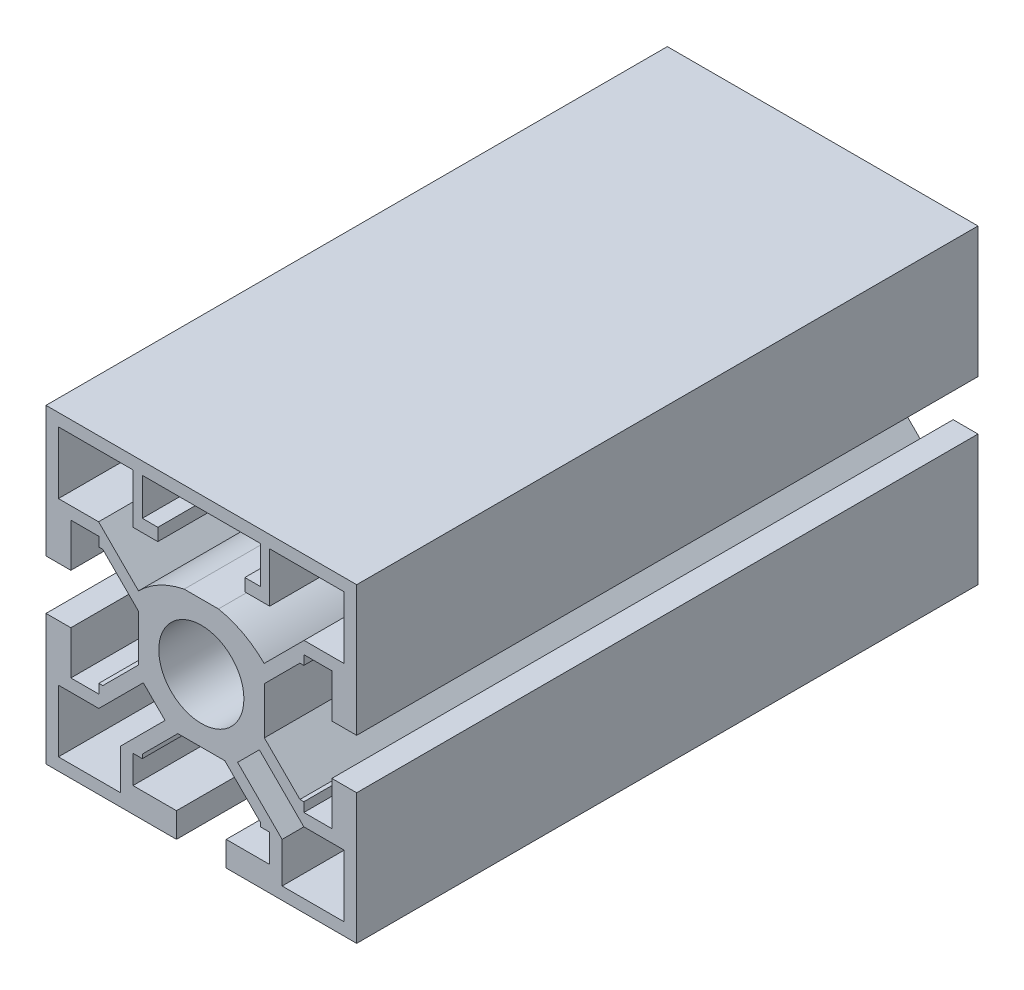
from build123d import *

# Parameters (mm, degrees)
SKETCH_A01_8_R     = 6.85
SKETCH_A01_8_W     = 10
SKETCH_A01_8_H     = 10
EXTRUDE1_DEPTH     = 100
CUT_EXTRUDE1_DEPTH = 101
CIRPATTERN1_COUNT  = 2
CIRPATTERN1_ANGLE  = 90
CUT_EXTRUDE2_DEPTH = 101
EXTRUDE3_DEPTH     = 100


with BuildPart() as part:
    # Sketch A01-8 → Extrude1 (new body)
    with BuildSketch(Plane.XY):
        Polygon((-16.5, -11), (-16.5, -9.5), (-15.863961, -9.5), (-10.14602885, -3.78206785), (-10.14602885, 3.78206785), (-15.863961, 9.5), (-16.5, 9.5), (-16.5, 11), (-21, 11), (-21, 4), (-25, 4), (-25, 25), (25, 25), (25, 4), (21, 4), (21, 11), (16.5, 11), (16.5, 9.5), (15.863961, 9.5), (10.14602885, 3.78206785), (10.14602885, -3.78206785), (15.863961, -9.5), (16.5, -9.5), (16.5, -11), (21, -11), (21, -4), (25, -4), (25, -25), (4, -25), (4, -21), (11, -21), (11, -16.5), (9.5, -16.5), (9.5, -15.863961), (3.78206785, -10.14602885), (-3.78206785, -10.14602885), (-9.5, -15.863961), (-9.5, -16.5), (-11, -16.5), (-11, -21), (-4, -21), (-4, -25), (-25, -25), (-25, -4), (-21, -4), (-21, -11), align=None)
        Circle(SKETCH_A01_8_R, mode=Mode.SUBTRACT)
        with Locations((-18, -18)):
            Rectangle(SKETCH_A01_8_W, SKETCH_A01_8_H, mode=Mode.SUBTRACT)
        with Locations((18, -18)):
            Rectangle(SKETCH_A01_8_W, SKETCH_A01_8_H, mode=Mode.SUBTRACT)
        Polygon((23, 13), (16.535534, 13), (14.035536811, 10.500002811), (-14.035536811, 10.500002811), (-16.535534, 13), (-23, 13), (-23, 23), (23, 23), align=None, mode=Mode.SUBTRACT)
    extrude(amount=-EXTRUDE1_DEPTH)

    # Sketch1 → Cut-Extrude1 (cut, through all)
    with BuildSketch(Plane.XY):
        Polygon((-16.5, -13), (-9.340048075, -5.840048075), (-5.840048075, -9.340048075), (-13, -16.5), align=None)
    cut_extrude1 = extrude(amount=-CUT_EXTRUDE1_DEPTH, mode=Mode.SUBTRACT)

    # CirPattern1: Cut-Extrude1 ×2 about axis
    cirpattern1_axis = Axis((0, 0, 0), (0, 0, 1))
    for i in range(1, CIRPATTERN1_COUNT):
        add(cut_extrude1.rotate(cirpattern1_axis, i * CIRPATTERN1_ANGLE / (CIRPATTERN1_COUNT - 1)), mode=Mode.SUBTRACT)

    # Sketch2 → Cut-Extrude2 (cut, through all)
    with BuildSketch(Plane.XY):
        with BuildLine():
            Line((-14.035536811, 10.500002811), (-10.114441476, 6.578907476))
            ThreePointArc((-10.114441476, 6.578907476), (0, 10.768446311), (10.114441476, 6.578907476))
            Line((10.114441476, 6.578907476), (14.035536811, 10.500002811))
            ThreePointArc((14.035536811, 10.500002811), (0, 16.313712513), (-14.035536811, 10.500002811))
        make_face()
    extrude(amount=-CUT_EXTRUDE2_DEPTH, mode=Mode.SUBTRACT)

    # Sketch3 → Extrude3 (add, through all)
    with BuildSketch(Plane.XY):
        Polygon((-11, 23), (-11, 15), (-7, 15), (-7, 17), (-9.5, 17), (-9.5, 23), align=None)
        Polygon((11, 23), (11, 15), (7, 15), (7, 17), (9.5, 17), (9.5, 23), align=None)
    extrude(amount=-EXTRUDE3_DEPTH)


solid = part.part
